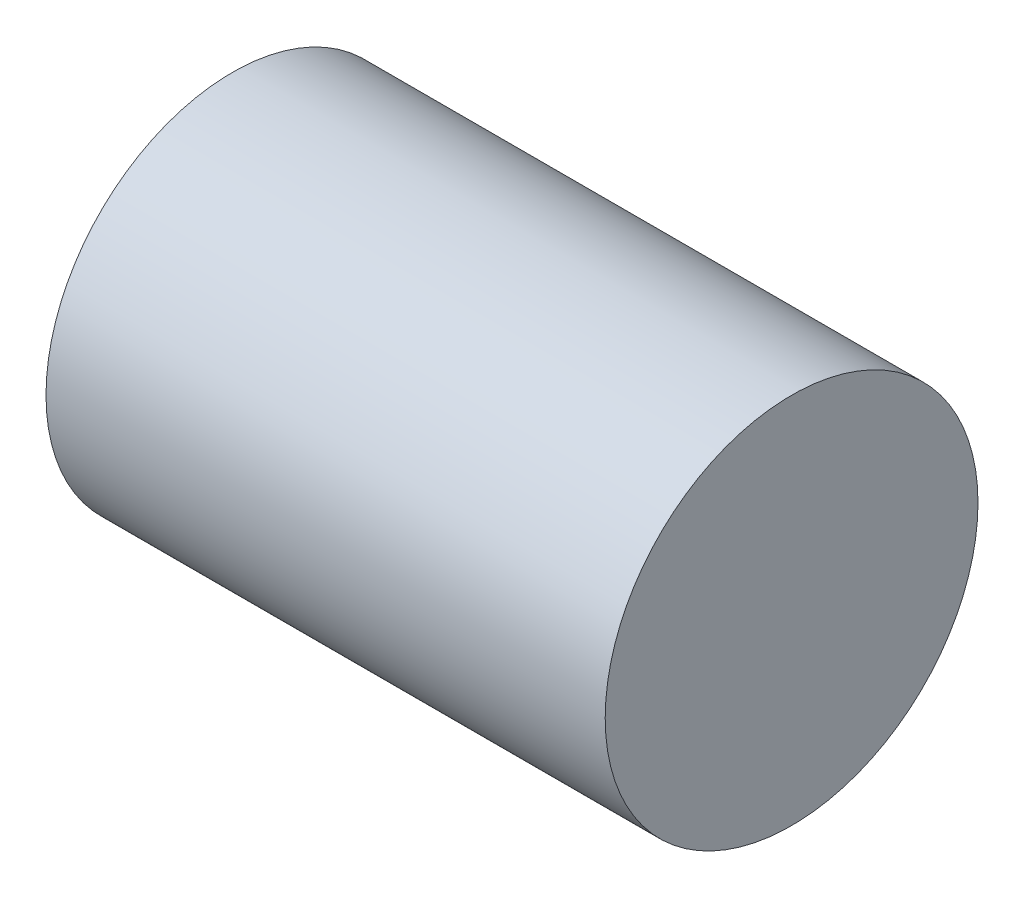
from build123d import *

# Parameters (mm, degrees)
SKETCH_1_R      = 2
EXTRUDE_1_DEPTH = 3


with BuildPart() as part:
    # 草圖1 → 填料-伸長1 (new body, symmetric)
    with BuildSketch(Plane(origin=(0, 0, 0), x_dir=(0, 0, -1), z_dir=(1, 0, 0))):
        Circle(SKETCH_1_R)
    extrude(amount=EXTRUDE_1_DEPTH, both=True)


solid = part.part
